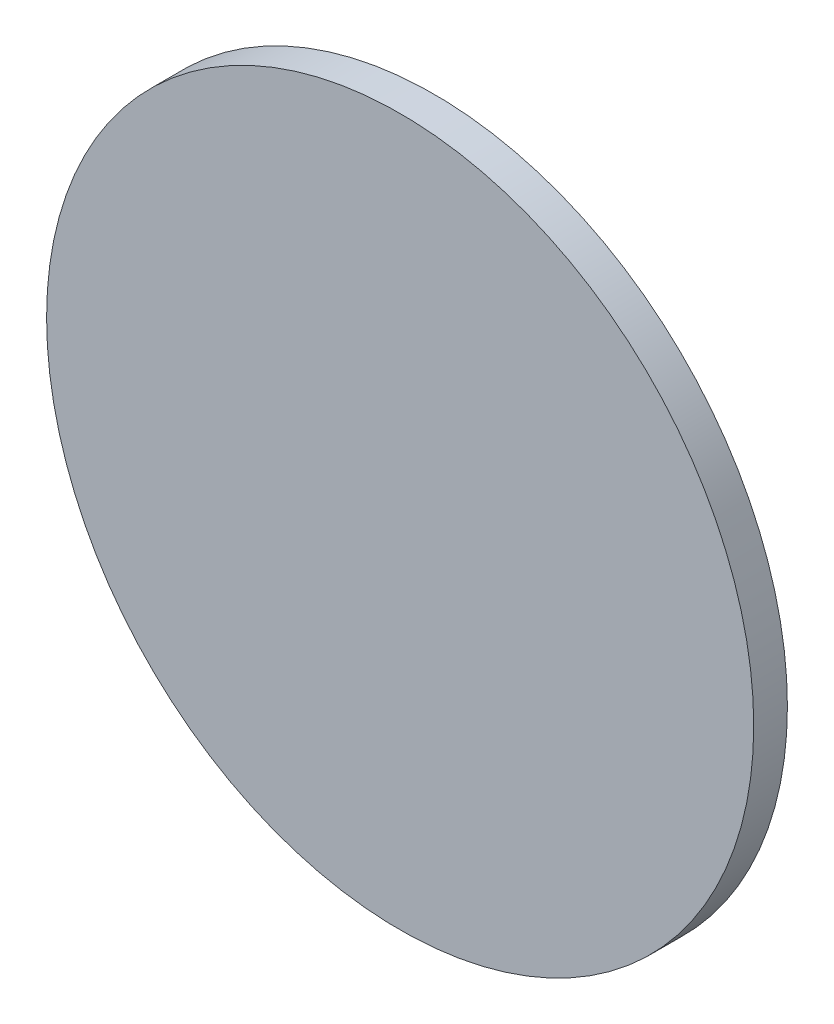
from build123d import *

# Parameters (mm, degrees)
SKETCH1_R           = 53.34
BOSS_EXTRUDE1_DEPTH = 5.08


with BuildPart() as part:
    # Sketch1 → Boss-Extrude1 (new body)
    with BuildSketch(Plane.XY):
        Circle(SKETCH1_R)
    extrude(amount=BOSS_EXTRUDE1_DEPTH)


solid = part.part
